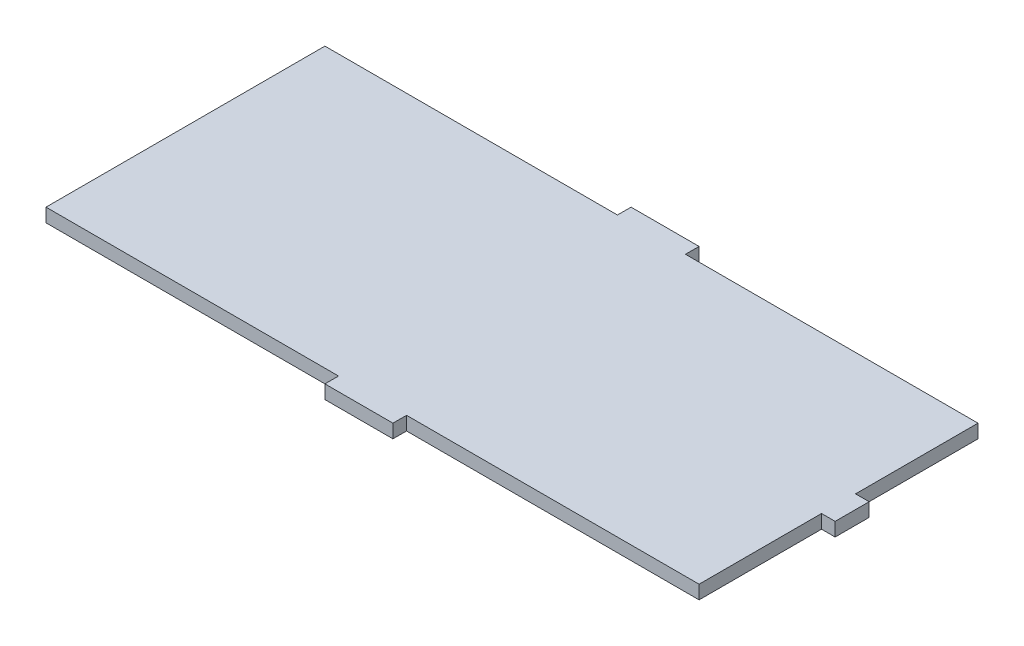
from build123d import *

# Parameters (mm, degrees)
BOSS_EXTRUDE1_DEPTH = 2


with BuildPart() as part:
    # Sketch1 → Boss-Extrude1 (new body)
    with BuildSketch(Plane(origin=(0, 0, 0), x_dir=(1, 0, 0), z_dir=(0, 1, 0))):
        Polygon((0, 0), (43, 0), (43, -2), (53, -2), (53, 0), (96, 0), (96, 18), (98, 18), (98, 23), (96, 23), (96, 41), (53, 41), (53, 43), (43, 43), (43, 41), (0, 41), align=None)
    extrude(amount=BOSS_EXTRUDE1_DEPTH)


solid = part.part
